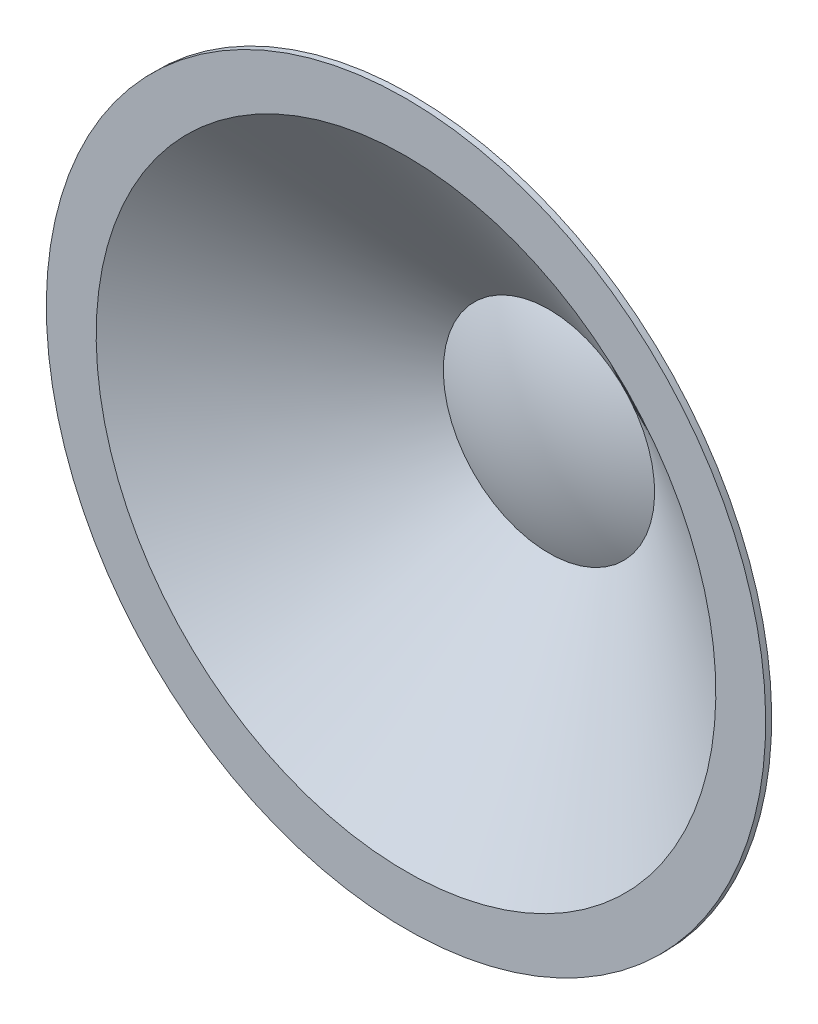
from build123d import *


with BuildPart() as part:
    # Sketch1 → Revolve-Thin1 (revolve)
    with BuildSketch(Plane(origin=(0, 0, 0), x_dir=(0, 0, -1), z_dir=(1, 0, 0))):
        with BuildLine():
            Line((0, 30), (0, 26))
            Line((0, 26), (12, 8.862223919))
            ThreePointArc((12, 8.862223919), (10.506209129, 4.542549196), (10, 0))
            Line((10, 0), (9.5, 0))
            ThreePointArc((9.5, 0), (9.986787691, 4.509912766), (11.42472682, 8.812075766))
            Line((11.42472682, 8.812075766), (-0.5, 25.842350606))
            Line((-0.5, 25.842350606), (-0.5, 30))
            Line((-0.5, 30), (0, 30))
        make_face()
    revolve(axis=Axis((0, 0, -12), (0, 0, 1)))


solid = part.part
